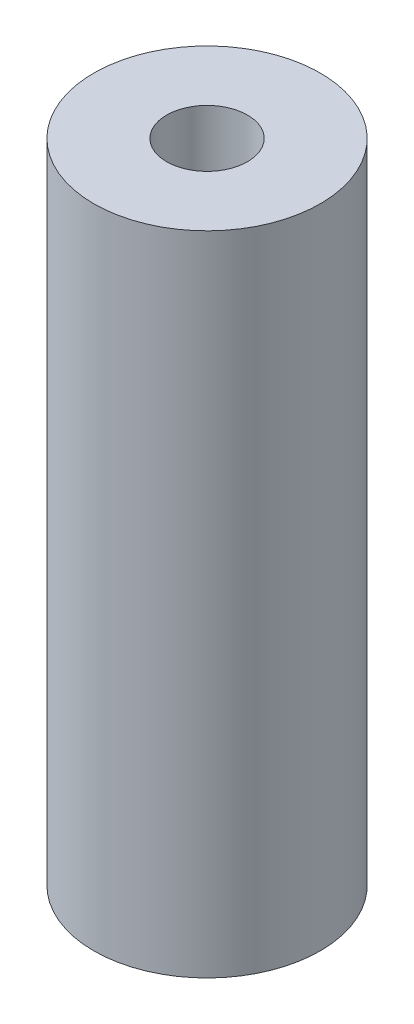
from build123d import *

# Parameters (mm, degrees)
SKETCH1_R           = 7
SKETCH1_R_2         = 2.5
BOSS_EXTRUDE1_DEPTH = 40


with BuildPart() as part:
    # Sketch1 → Boss-Extrude1 (new body)
    with BuildSketch(Plane(origin=(0, 0, 0), x_dir=(1, 0, 0), z_dir=(0, 1, 0))):
        Circle(SKETCH1_R)
        Circle(SKETCH1_R_2, mode=Mode.SUBTRACT)
    extrude(amount=BOSS_EXTRUDE1_DEPTH)


solid = part.part
